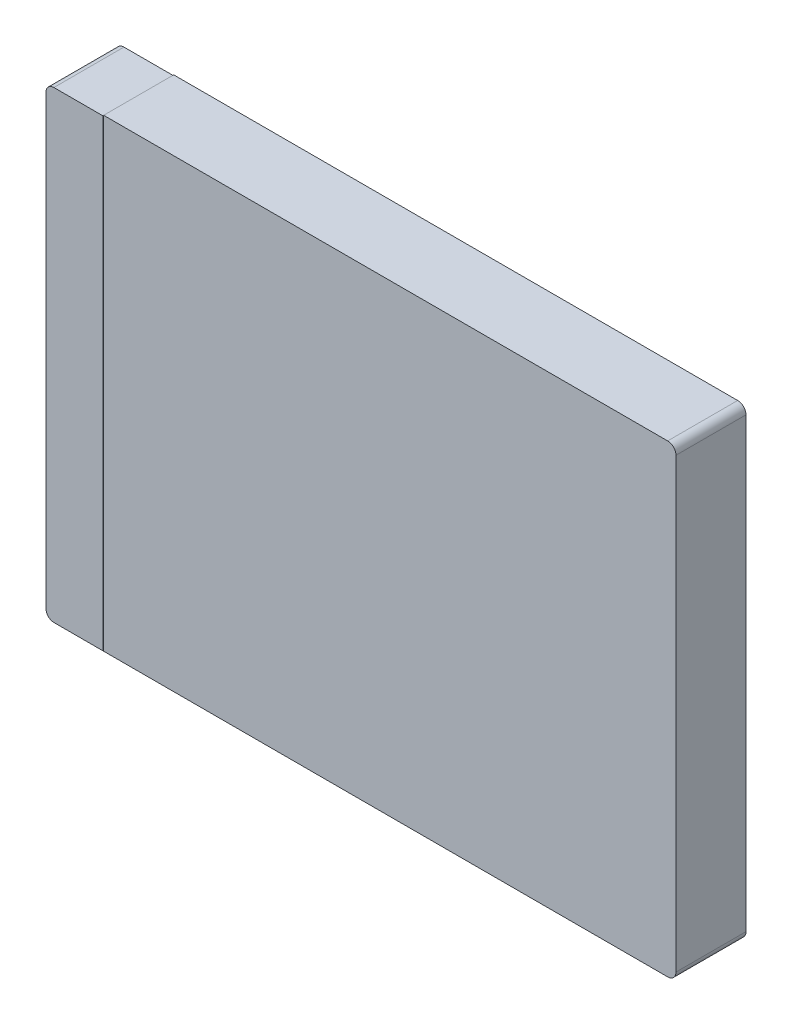
from build123d import *

# Parameters (mm, degrees)
SKETCH1_W           = 38.608
SKETCH1_H           = 28.448
BOSS_EXTRUDE1_DEPTH = 4.318
FILLET1_R           = 0.508
CUT_EXTRUDE1_DEPTH  = 0.0254
CUT_EXTRUDE2_DEPTH  = 5.318
SKETCH4_W           = 40.052810536
SKETCH4_H           = 38.466208511
CUT_EXTRUDE3_DEPTH  = 0.0254


with BuildPart() as part:
    # Sketch1 → Boss-Extrude1 (new body)
    with BuildSketch(Plane.XY):
        with Locations((-11.737014375, -14.438872145)):
            Rectangle(SKETCH1_W, SKETCH1_H)
    extrude(amount=BOSS_EXTRUDE1_DEPTH)

    # Fillet1
    fillet1_edges = [part.edges().sort_by_distance(p)[0] for p in [
        (-31.041014375, -0.214872145, 2.159),
        (7.566985625, -0.214872145, 2.159),
        (7.566985625, -28.662872145, 2.159),
        (-31.041014375, -28.662872145, 2.159),
    ]]
    fillet(fillet1_edges, radius=FILLET1_R)

    # Sketch2 → Cut-Extrude1 (cut)
    with BuildSketch(Plane(origin=(0, 0, 0), x_dir=(-1, 0, 0), z_dir=(0, 0, -1))):
        with BuildLine():
            Line((30.533014375, -0.240272145), (27.508194832, -0.240272145))
            Line((27.508194832, -0.240272145), (27.508194832, -28.637472145))
            Line((27.508194832, -28.637472145), (30.533014375, -28.637472145))
            ThreePointArc((30.533014375, -28.637472145), (30.874264108, -28.496121878), (31.015614375, -28.154872145))
            Line((31.015614375, -28.154872145), (31.015614375, -0.722872145))
            ThreePointArc((31.015614375, -0.722872145), (30.874264108, -0.381622412), (30.533014375, -0.240272145))
        make_face()
    extrude(amount=-CUT_EXTRUDE1_DEPTH, mode=Mode.SUBTRACT)

    # Sketch3 → Cut-Extrude2 (cut, through all)
    with BuildSketch(Plane(origin=(0, 0, 0), x_dir=(-1, 0, 0), z_dir=(0, 0, -1))):
        with BuildLine():
            Line((30.533014375, -0.214872145), (27.508194832, -0.214872145))
            Line((27.508194832, -0.214872145), (27.508194832, -0.240272145))
            Line((27.508194832, -0.240272145), (30.533014375, -0.240272145))
            ThreePointArc((30.533014375, -0.240272145), (30.874264108, -0.381622412), (31.015614375, -0.722872145))
            Line((31.015614375, -0.722872145), (31.015614375, -28.154872145))
            ThreePointArc((31.015614375, -28.154872145), (30.874264108, -28.496121878), (30.533014375, -28.637472145))
            Line((30.533014375, -28.637472145), (27.508194832, -28.637472145))
            Line((27.508194832, -28.637472145), (27.508194832, -28.662872145))
            Line((27.508194832, -28.662872145), (30.533014375, -28.662872145))
            ThreePointArc((30.533014375, -28.662872145), (30.89222462, -28.51408239), (31.041014375, -28.154872145))
            Line((31.041014375, -28.154872145), (31.041014375, -0.722872145))
            ThreePointArc((31.041014375, -0.722872145), (30.89222462, -0.3636619), (30.533014375, -0.214872145))
        make_face()
    extrude(amount=-CUT_EXTRUDE2_DEPTH, mode=Mode.SUBTRACT)

    # Sketch4 → Cut-Extrude3 (cut)
    with BuildSketch(Plane.XY.offset(4.318)):
        with Locations((-7.481789564, -12.895374115)):
            Rectangle(SKETCH4_W, SKETCH4_H)
    extrude(amount=-CUT_EXTRUDE3_DEPTH, mode=Mode.SUBTRACT)


solid = part.part
